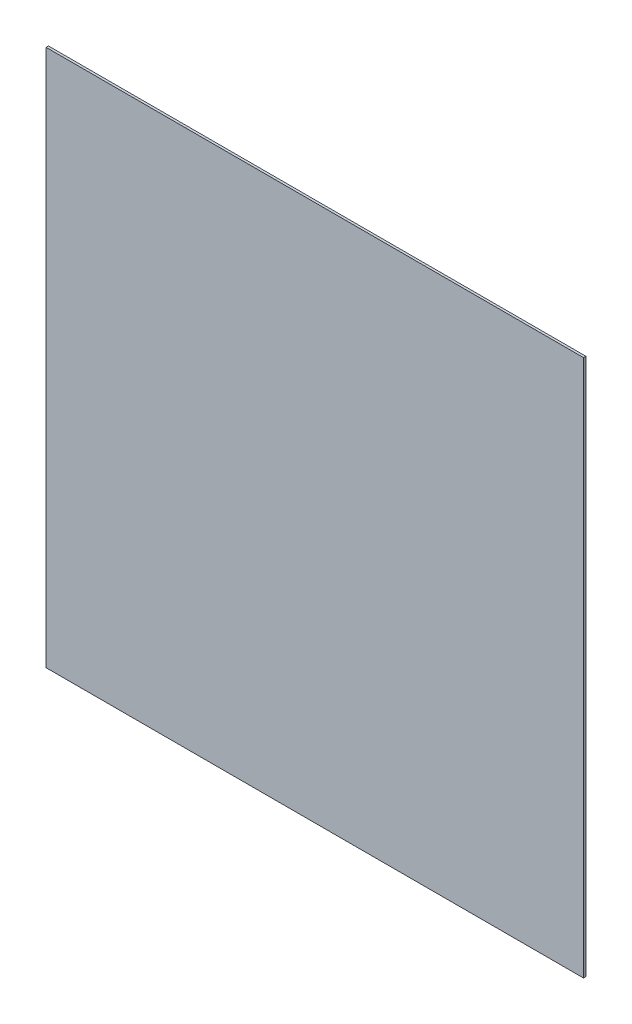
from build123d import *

# Parameters (mm, degrees)
SKETCH1_W           = 300
SKETCH1_H           = 300
BOSS_EXTRUDE1_DEPTH = 1.325


with BuildPart() as part:
    # Sketch1 → Boss-Extrude1 (new body)
    with BuildSketch(Plane.XY):
        Rectangle(SKETCH1_W, SKETCH1_H)
    extrude(amount=BOSS_EXTRUDE1_DEPTH)


solid = part.part
